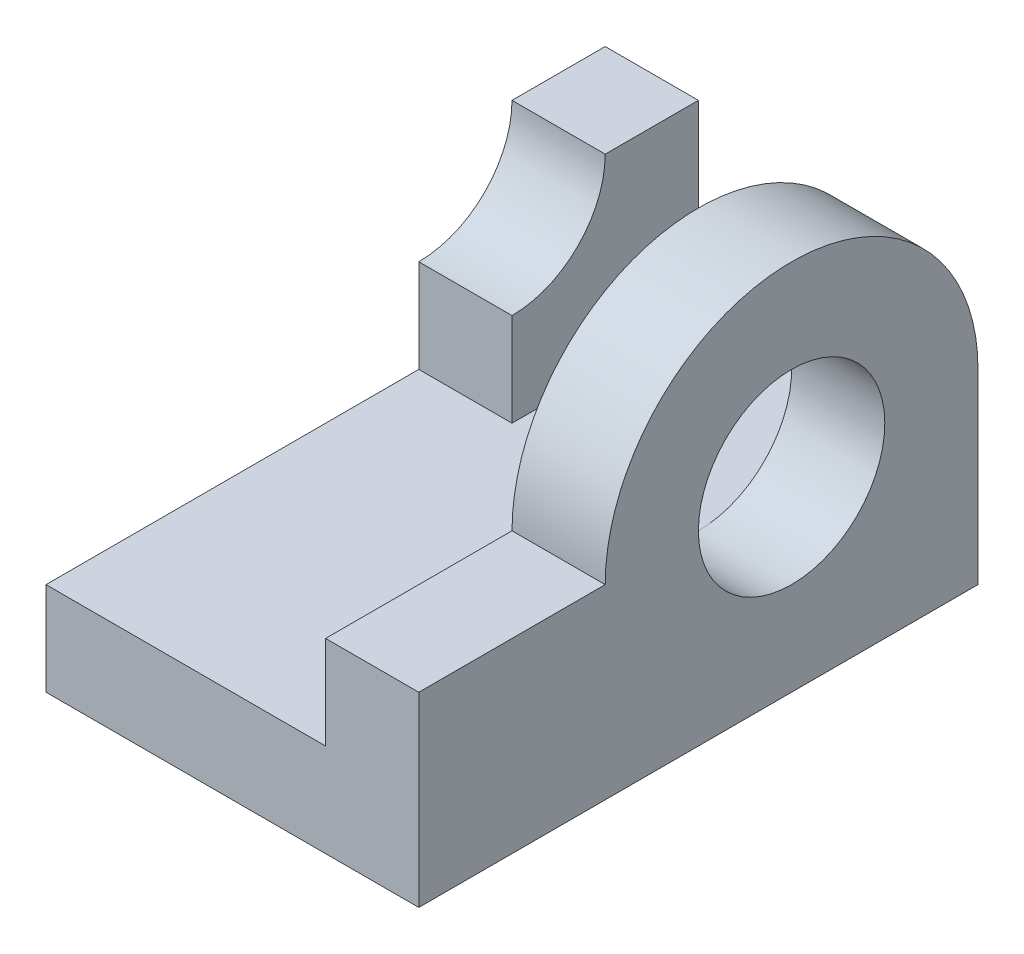
from build123d import *

# Parameters (mm, degrees)
CROQUIS1_R              = 10
SALIENTE_EXTRUIR1_DEPTH = 10
SALIENTE_EXTRUIR2_DEPTH = 30
SALIENTE_EXTRUIR3_DEPTH = 10
SALIENTE_EXTRUIR4_DEPTH = 10


with BuildPart() as part:
    # Croquis1 → Saliente-Extruir1 (new body)
    with BuildSketch(Plane(origin=(0, 0, 0), x_dir=(0, 0, -1), z_dir=(1, 0, 0))):
        with BuildLine():
            Line((-40, -20), (0, -20))
            ThreePointArc((0, -20), (14.142135624, 14.142135624), (-20, 0))
            Line((-20, 0), (-40, 0))
            Line((-40, 0), (-40, -20))
        make_face()
        Circle(CROQUIS1_R, mode=Mode.SUBTRACT)
    extrude(amount=SALIENTE_EXTRUIR1_DEPTH)

    # Croquis2 → Saliente-Extruir2 (add)
    with BuildSketch(Plane.ZY):
        with BuildLine():
            Line((-17.320508076, -10), (-20, -10))
            Line((-20, -10), (-20, -20))
            Line((-20, -20), (0, -20))
            ThreePointArc((0, -20), (-10, -17.320508076), (-17.320508076, -10))
        make_face()
        with BuildLine():
            Line((40, -10), (-17.320508076, -10))
            ThreePointArc((-17.320508076, -10), (-10, -17.320508076), (0, -20))
            Line((0, -20), (40, -20))
            Line((40, -20), (40, -10))
        make_face()
    extrude(amount=SALIENTE_EXTRUIR2_DEPTH)

    # Croquis3 → Saliente-Extruir3 (add)
    with BuildSketch(Plane(origin=(10, 0, 0), x_dir=(0, 0, -1), z_dir=(1, 0, 0))):
        Polygon((0, -20), (20, -20), (20, 0), align=None)
    extrude(amount=-SALIENTE_EXTRUIR3_DEPTH)

    # Croquis4 → Saliente-Extruir4 (add)
    with BuildSketch(Plane.ZY.offset(30)):
        with BuildLine():
            Line((-20, -10), (-20, 10))
            Line((-20, 10), (-10, 10))
            ThreePointArc((-10, 10), (-7.071067812, 2.928932188), (0, 0))
            Line((0, 0), (0, -10))
            Line((0, -10), (-20, -10))
        make_face()
    extrude(amount=-SALIENTE_EXTRUIR4_DEPTH)


solid = part.part
